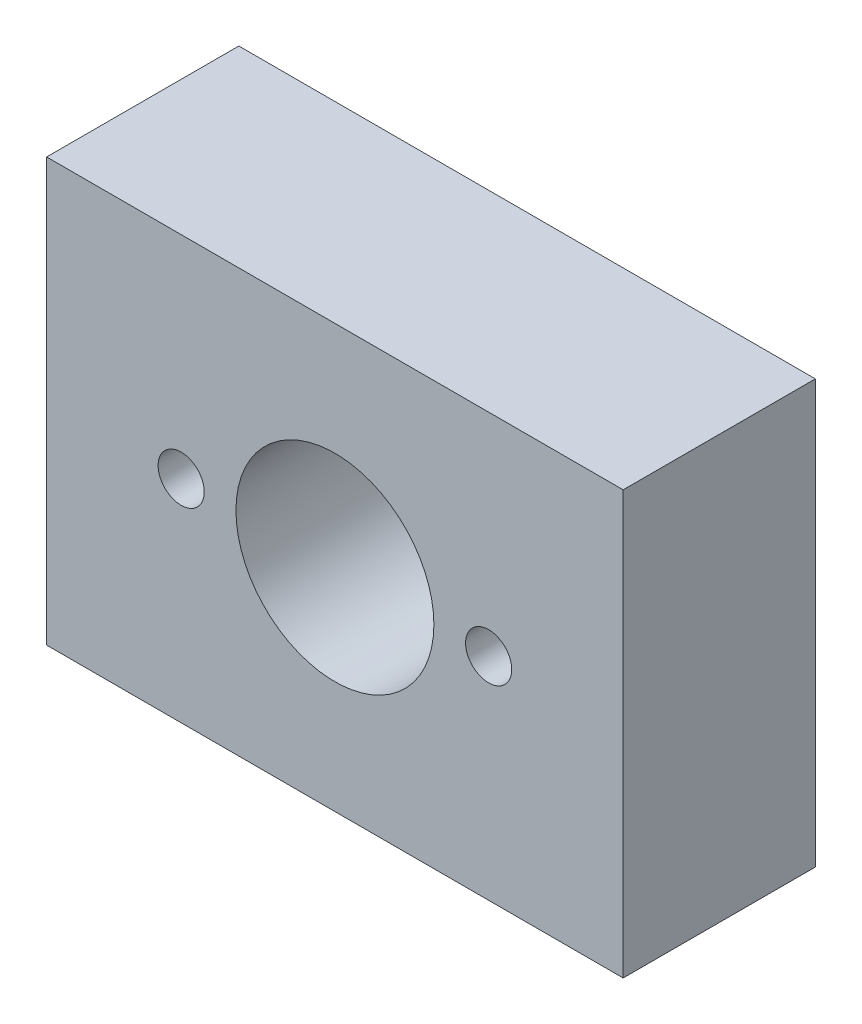
from build123d import *

# Parameters (mm, degrees)
SKETCH1_W           = 30
SKETCH1_H           = 22
SKETCH1_R           = 5.15
BOSS_EXTRUDE1_DEPTH = 10
SKETCH2_R           = 2
CUT_EXTRUDE1_DEPTH  = 10
SKETCH7_R           = 1.2
CUT_EXTRUDE2_DEPTH  = 11


with BuildPart() as part:
    # Sketch1 → Boss-Extrude1 (new body)
    with BuildSketch(Plane.XY):
        Rectangle(SKETCH1_W, SKETCH1_H)
        Circle(SKETCH1_R, mode=Mode.SUBTRACT)
    extrude(amount=BOSS_EXTRUDE1_DEPTH)

    # Sketch2 → Cut-Extrude1 (cut)
    with BuildSketch(Plane.XZ.offset(11)):
        with Locations((-11, 5)):
            Circle(SKETCH2_R)
        with Locations((11, 5)):
            Circle(SKETCH2_R)
    extrude(amount=-CUT_EXTRUDE1_DEPTH, mode=Mode.SUBTRACT)

    # Sketch7 → Cut-Extrude2 (cut, through all)
    with BuildSketch(Plane.XY.offset(10)):
        with Locations((-8, 0)):
            Circle(SKETCH7_R)
        with Locations((8, 0)):
            Circle(SKETCH7_R)
    extrude(amount=-CUT_EXTRUDE2_DEPTH, mode=Mode.SUBTRACT)


solid = part.part
